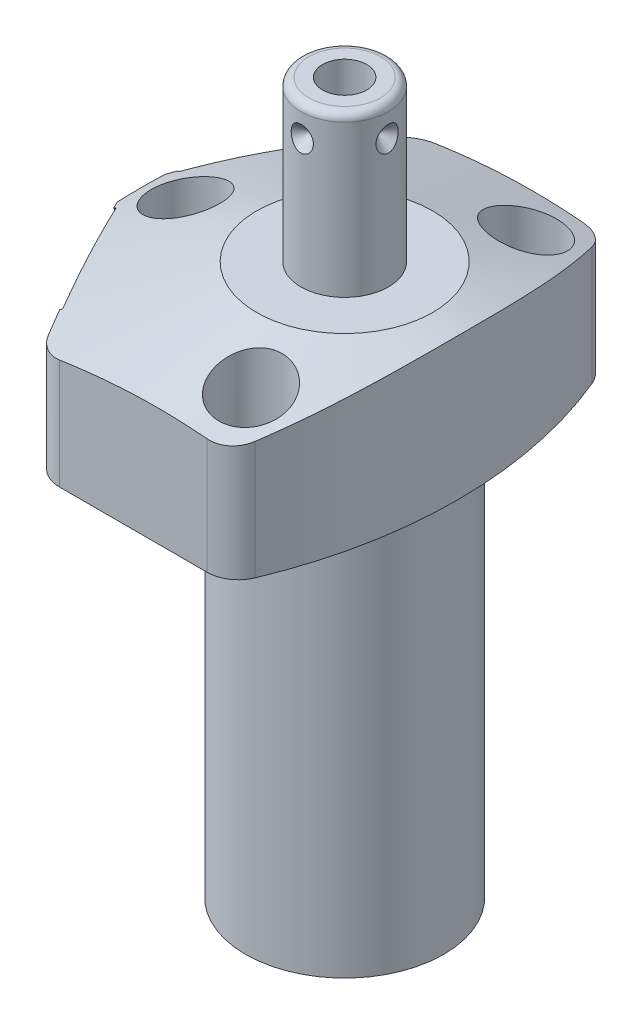
from build123d import *

# Parameters (mm, degrees)
CUT_EXTRUDE1_REACH = 21.05
CUT_EXTRUDE2_REACH = 21.05
S2D0002_OUTSIDE_W  = 78.27
S2D0002_OUTSIDE_H  = 69.906
CUT_EXTRUDE3_DEPTH = 26.035
FILLET1_R          = 3.9624
SKETCH17_R         = 10.4775
CUT_EXTRUDE4_DEPTH = 0.254
SKETCH18_R         = 10.4775
CUT_EXTRUDE5_DEPTH = 0.254
SKETCH19_R         = 5.5626
CUT_EXTRUDE6_DEPTH = 2.667
CIRPATTERN1_COUNT  = 4
HOLE1_D            = 5.5626
HOLE1_DEPTH        = 19.05
HOLE1_CBORE_D      = 8.7122
HOLE1_CBORE_DEPTH  = 11.0998


with BuildPart() as part:
    # Sketch1 → Revolve1 (revolve)
    with BuildSketch(Plane(origin=(0, 0, 0), x_dir=(0, -1, 0), z_dir=(0, 0, 1)), mode=Mode.PRIVATE) as revolve1_sk:
        Polygon((0, 28.575), (-19.05, 28.575), (-19.05, 0), (50.8, 0), (50.8, 12.573), (0, 12.573), align=None)
    revolve(revolve1_sk.sketch.rotate(Axis((0, 22.5425, 0), (0, -1, 0)), 90), axis=Axis((0, 22.5425, 0), (0, -1, 0)))  # turned: the seam where the file's is

    # Sketch2 → Cut-Extrude1 (cut, up to next)
    with BuildSketch(Plane(origin=(0, 0, 0), x_dir=(0, 0, -1), z_dir=(0, -1, 0)), mode=Mode.PRIVATE) as cut_extrude1_sk1:
        with BuildLine():
            Line((23.8125, -15.795425564), (23.8125, 15.795425564))
            ThreePointArc((23.8125, 15.795425564), (28.575, 0), (23.8125, -15.795425564))
        make_face()
    cut_extrude1_tool1 = extrude(cut_extrude1_sk1.sketch, amount=-CUT_EXTRUDE1_REACH, mode=Mode.PRIVATE) & part.part
    add(cut_extrude1_tool1.solids().sort_by_distance((0, 0, -25.731798))[0], mode=Mode.SUBTRACT)
    # Sketch2 → Cut-Extrude1 (cut, up to next)
    with BuildSketch(Plane(origin=(0, 0, 0), x_dir=(0, 0, -1), z_dir=(0, -1, 0)), mode=Mode.PRIVATE) as cut_extrude1_sk2:
        with BuildLine():
            Line((-23.8125, 15.795425564), (-23.8125, -15.795425564))
            ThreePointArc((-23.8125, -15.795425564), (-28.575, 0), (-23.8125, 15.795425564))
        make_face()
    cut_extrude1_tool2 = extrude(cut_extrude1_sk2.sketch, amount=-CUT_EXTRUDE1_REACH, mode=Mode.PRIVATE) & part.part
    add(cut_extrude1_tool2.solids().sort_by_distance((0, 0, 25.731798))[0], mode=Mode.SUBTRACT)

    # Sketch3 → Cut-Extrude2 (cut, up to next)
    with BuildSketch(Plane(origin=(0, 0, 0), x_dir=(-1, 0, 0), z_dir=(0, -1, 0)), mode=Mode.PRIVATE) as cut_extrude2_sk1:
        with BuildLine():
            Line((14.75388632, 23.8125), (27.415217161, 0))
            Line((27.415217161, 0), (14.75388632, -23.8125))
            Line((14.75388632, -23.8125), (15.795425564, -23.8125))
            ThreePointArc((15.795425564, -23.8125), (28.575, 0), (15.795425564, 23.8125))
            Line((15.795425564, 23.8125), (14.75388632, 23.8125))
        make_face()
    cut_extrude2_tool1 = extrude(cut_extrude2_sk1.sketch, amount=-CUT_EXTRUDE2_REACH, mode=Mode.PRIVATE) & part.part
    add(cut_extrude2_tool1.solids().sort_by_distance((-15.274656, 0, -23.3166))[0], mode=Mode.SUBTRACT)

    # S2D0002 outside → Cut-Extrude3 (cut)
    with BuildSketch(Plane(origin=(0, 0, 0), x_dir=(-1, 0, 0), z_dir=(0, -1, 0))):
        with Locations((-0.58, 0)):
            Rectangle(S2D0002_OUTSIDE_W, S2D0002_OUTSIDE_H)
        with BuildLine():
            Line((25.8064, 53.379071452), (25.8064, -53.379071452))
            ThreePointArc((25.8064, -53.379071452), (-14.3002, 0), (25.8064, 53.379071452))
        make_face(mode=Mode.SUBTRACT)
    extrude(amount=-CUT_EXTRUDE3_DEPTH, mode=Mode.SUBTRACT)

    # Fillet1
    fillet1_edges = [part.edges().sort_by_distance(p)[0] for p in [
        (-14.75388632, 9.525, 23.8125),
        (-14.75388632, 9.525, -23.8125),
        (8.940213818, 9.525, 23.8125),
        (8.940213818, 9.525, -23.8125),
    ]]
    fillet(fillet1_edges, radius=FILLET1_R)

    # Sketch5 → Cut-Revolve1 (revolve, cut)
    with BuildSketch(Plane.XY, mode=Mode.PRIVATE) as cut_revolve1_sk:
        Polygon((-11.176, 19.05), (-44.45, 8.238622028), (-44.45, 19.05), align=None)
    revolve(cut_revolve1_sk.sketch.rotate(Axis((0, 5.998428823, 0), (0, 1, 0)), 90), axis=Axis((0, 5.998428823, 0), (0, 1, 0)), mode=Mode.SUBTRACT)  # turned: the seam where the file's is

    # Sketch6 → Cut-Revolve2 (revolve, cut)
    with BuildSketch(Plane(origin=(-21.148537334, 7.9502, -11.244876766), x_dir=(0.469471563, 0, -0.882947593), z_dir=(0, 1, 0))):
        Polygon((0, 0), (4.5466, 0), (4.106586662, -2.0701), (3.4544, -2.722286662), (3.4544, -12.192), (0, -12.192), align=None)
    revolve(axis=Axis((-9.845395429, 7.9502, -5.234889608), (-0.882947593, 0, -0.469471563)), mode=Mode.SUBTRACT)

    # Sketch7 → Cut-Revolve3 (revolve, cut)
    with BuildSketch(Plane(origin=(-21.148537334, 7.9502, 11.244876766), x_dir=(-0.469471563, 0, -0.882947593), z_dir=(0, 1, 0))):
        Polygon((0, 0), (4.5466, 0), (4.106586662, -2.0701), (3.4544, -2.722286662), (3.4544, -12.192), (0, -12.192), align=None)
    revolve(axis=Axis((-9.845395429, 7.9502, 5.234889608), (-0.882947593, 0, 0.469471563)), mode=Mode.SUBTRACT)

    # Sketch17 → Cut-Extrude4 (cut)
    with BuildSketch(Plane(origin=(-21.372806022, 0, 11.364122543), x_dir=(0.469471563, 0, 0.882947593), z_dir=(-0.882947593, 0, 0.469471563))):
        with Locations((0, 7.9502)):
            Circle(SKETCH17_R)
    extrude(amount=-CUT_EXTRUDE4_DEPTH, mode=Mode.SUBTRACT)

    # Sketch18 → Cut-Extrude5 (cut)
    with BuildSketch(Plane(origin=(-21.372806022, 0, -11.364122543), x_dir=(-0.469471563, 0, 0.882947593), z_dir=(-0.882947593, 0, -0.469471563))):
        with Locations((0, 7.9502)):
            Circle(SKETCH18_R)
    extrude(amount=-CUT_EXTRUDE5_DEPTH, mode=Mode.SUBTRACT)

    # Sketch8 → Cut-Revolve4 (revolve, cut)
    with BuildSketch(Plane(origin=(-11.1252, 2.667, -15.875), x_dir=(-1, 0, 0), z_dir=(0, 0, 1)), mode=Mode.PRIVATE) as cut_revolve4_sk:
        Polygon((0, 0), (4.5466, 0), (4.106586662, -2.0701), (3.4544, -2.722286662), (3.4544, -11.684), (0, -11.684), align=None)
    revolve(cut_revolve4_sk.sketch.rotate(Axis((-11.1252, 14.9352, -15.875), (0, -1, 0)), 270), axis=Axis((-11.1252, 14.9352, -15.875), (0, -1, 0)), mode=Mode.SUBTRACT)  # turned: the seam where the file's is

    # Sketch9 → Cut-Revolve5 (revolve, cut)
    with BuildSketch(Plane(origin=(-11.1252, 2.667, 15.875), x_dir=(-1, 0, 0), z_dir=(0, 0, 1)), mode=Mode.PRIVATE) as cut_revolve5_sk:
        Polygon((0, 0), (4.5466, 0), (4.106586662, -2.0701), (3.4544, -2.722286662), (3.4544, -11.684), (0, -11.684), align=None)
    revolve(cut_revolve5_sk.sketch.rotate(Axis((-11.1252, 14.9352, 15.875), (0, -1, 0)), 270), axis=Axis((-11.1252, 14.9352, 15.875), (0, -1, 0)), mode=Mode.SUBTRACT)  # turned: the seam where the file's is

    # Sketch10 → Revolve2 (revolve)
    with BuildSketch(Plane(origin=(0, 0, 0), x_dir=(0, 0, -1), z_dir=(1, 0, 0)), mode=Mode.PRIVATE) as revolve2_sk:
        with BuildLine():
            Line((0, 19.05), (-5.55625, 19.05))
            Line((-5.55625, 19.05), (-5.55625, 38.3032))
            ThreePointArc((-5.55625, 38.3032), (-5.25867049, 39.02162049), (-4.54025, 39.3192))
            Line((-4.54025, 39.3192), (0, 39.3192))
            Line((0, 39.3192), (0, 19.05))
        make_face()
    revolve(revolve2_sk.sketch.rotate(Axis((0, 18.03654, 0), (0, 1, 0)), 180), axis=Axis((0, 18.03654, 0), (0, 1, 0)))  # turned: the seam where the file's is

    # Sketch19 → Cut-Extrude6 (cut)
    with BuildSketch(Plane.XZ):
        with Locations(Location((-11.1252, -15.875, 0), (0, 0, 270))):  # turned: the seam where the file's is
            Circle(SKETCH19_R)
        with Locations(Location((-11.1252, 15.875, 0), (0, 0, 270))):  # turned: the seam where the file's is
            Circle(SKETCH19_R)
    extrude(amount=-CUT_EXTRUDE6_DEPTH, mode=Mode.SUBTRACT)

    # S2D0001 → Cut-Revolve6 (revolve, cut)
    with BuildSketch(Plane(origin=(2.8067, 39.3192, 0), x_dir=(1, 0, 0), z_dir=(0, 0, 1)), mode=Mode.PRIVATE) as cut_revolve6_sk:
        Polygon((0, 0), (0, -10.16), (-2.8067, -11.846435499), (-2.8067, 0), align=None)
    revolve(cut_revolve6_sk.sketch.rotate(Axis((0, 21.752471385, 0), (0, 1, 0)), 90), axis=Axis((0, 21.752471385, 0), (0, 1, 0)), mode=Mode.SUBTRACT)  # turned: the seam where the file's is

    # Sketch14 → Revolve3 (revolve)
    with BuildSketch(Plane(origin=(-11.1252, 0, 15.875), x_dir=(0, 0, -1), z_dir=(1, 0, 0))):
        with BuildLine():
            Line((5.461, 2.667), (5.461, 0.9398))
            Line((5.461, 0.9398), (5.301559456, 0.9398))
            ThreePointArc((5.301559456, 0.9398), (4.572, -0.4572), (3.842440544, 0.9398))
            Line((3.842440544, 0.9398), (3.175, 0.9398))
            ThreePointArc((3.175, 0.9398), (2.815789755, 0.791010245), (2.667, 0.4318))
            Line((2.667, 0.4318), (2.667, 0.127))
            Line((2.667, 0.127), (1.5875, 0.127))
            Line((1.5875, 0.127), (1.5875, 10.6172))
            Line((1.5875, 10.6172), (3.2512, 10.6172))
            Line((3.2512, 10.6172), (3.2512, 2.667))
            Line((3.2512, 2.667), (5.461, 2.667))
        make_face()
    revolve3 = revolve(axis=Axis((-11.1252, -1.01092, 15.875), (0, 1, 0)))

    # Sketch15 → Cut-Revolve7 (revolve, cut)
    with BuildSketch(Plane(origin=(-5.55625, 35.3568, 0), x_dir=(0, 1, 0), z_dir=(0, 0, 1)), mode=Mode.PRIVATE) as cut_revolve7_sk:
        Polygon((0, 0), (1.5875, 0), (0, -1.5875), align=None)
    cut_revolve7 = revolve(cut_revolve7_sk.sketch.rotate(Axis((-1.854476352, 35.3568, 0), (-1, 0, 0)), 270), axis=Axis((-1.854476352, 35.3568, 0), (-1, 0, 0)), mode=Mode.SUBTRACT)  # turned: the seam where the file's is

    # CirPattern1: Cut-Revolve7 ×4 about axis
    cirpattern1_axis = Axis((0, 18.03654, 0), (0, -1, 0))
    for i in range(1, CIRPATTERN1_COUNT):
        add(cut_revolve7.rotate(cirpattern1_axis, i * 360 / CIRPATTERN1_COUNT), mode=Mode.SUBTRACT)

    # Hole1
    with Locations(Plane(origin=(0, 19.05, 0), x_dir=(-1, 0, 0), z_dir=(0, 1, 0))):
        with Locations((-5.5626, -17.4498), (20.193, 0), (-5.5626, 17.4498)):
            CounterBoreHole(HOLE1_D / 2, HOLE1_CBORE_D / 2, HOLE1_CBORE_DEPTH, depth=HOLE1_DEPTH)

    # Mirror1: Revolve3 across plane
    add(revolve3.mirror(Plane.XY))


solid = part.part
